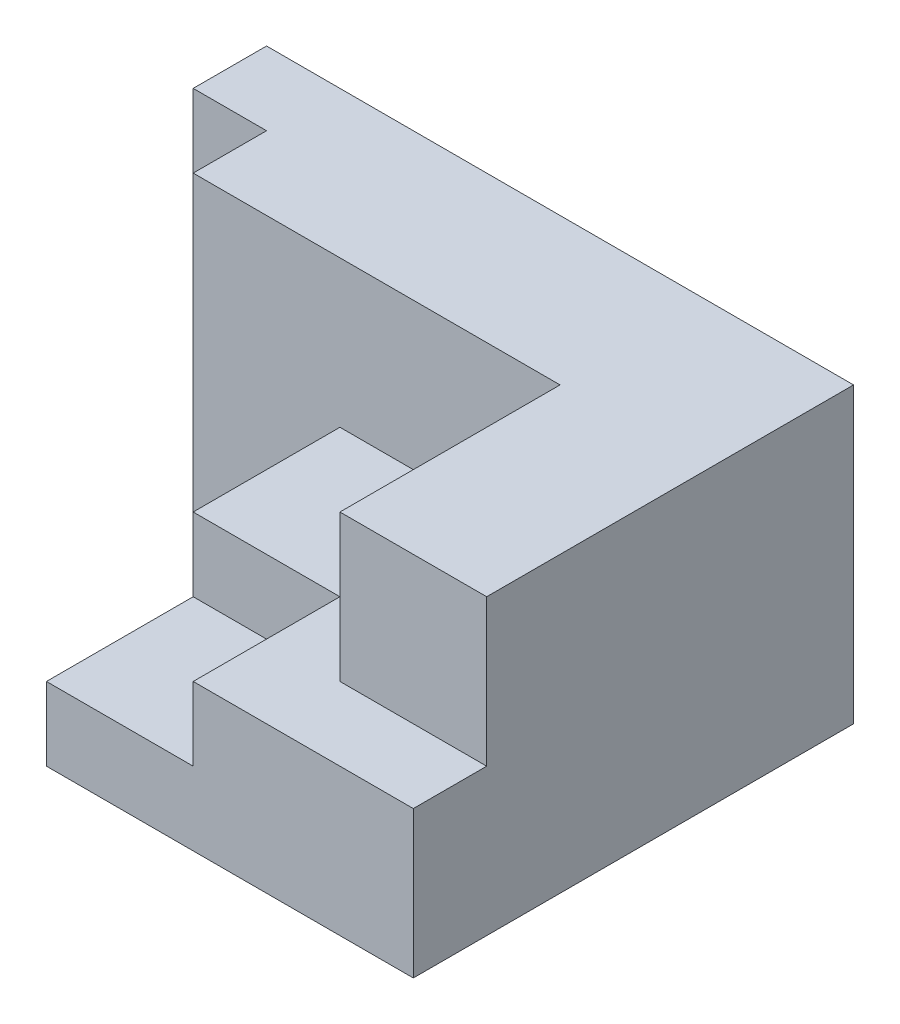
from build123d import *

# Parameters (mm, degrees)
BOSS_EXTRUDE2_DEPTH = 40
CUT_EXTRUDE1_DEPTH  = 20
SKETCH4_W           = 20
SKETCH4_H           = 20
CUT_EXTRUDE2_DEPTH  = 10


with BuildPart() as part:
    # Sketch2 → Boss-Extrude2 (new body)
    with BuildSketch(Plane(origin=(0, 0, 0), x_dir=(1, 0, 0), z_dir=(0, 1, 0))):
        Polygon((0, 0), (80, 0), (80, -60), (30, -60), (30, -20), (10, -20), (10, -10), (0, -10), align=None)
    extrude(amount=BOSS_EXTRUDE2_DEPTH)

    # Sketch3 → Cut-Extrude1 (cut)
    with BuildSketch(Plane(origin=(0, 40, 0), x_dir=(1, 0, 0), z_dir=(0, 1, 0))):
        Polygon((80, -52.352661089), (80, -60), (30, -60), (30, -20), (60, -20), (60, -50), (80, -50), align=None)
    extrude(amount=-CUT_EXTRUDE1_DEPTH, mode=Mode.SUBTRACT)

    # Sketch4 → Cut-Extrude2 (cut)
    with BuildSketch(Plane(origin=(0, 20, 0), x_dir=(1, 0, 0), z_dir=(0, 1, 0))):
        with Locations((40, -50)):
            Rectangle(SKETCH4_W, SKETCH4_H)
    extrude(amount=-CUT_EXTRUDE2_DEPTH, mode=Mode.SUBTRACT)


solid = part.part
